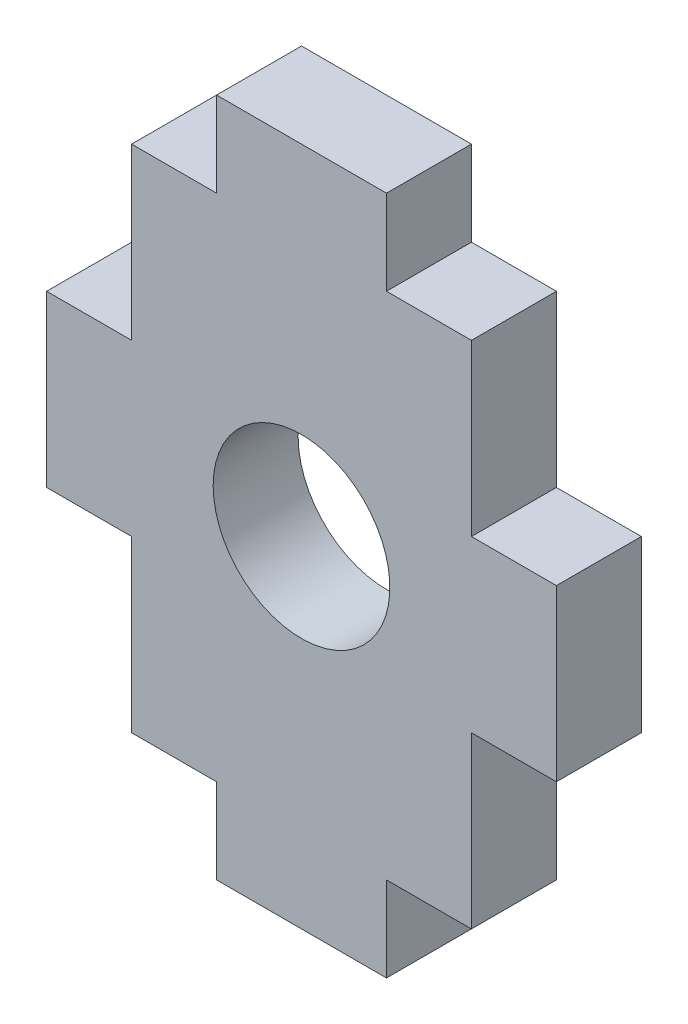
from build123d import *

# Parameters (mm, degrees)
EXTRUDE1_DEPTH     = 3.175
SKETCH2_R          = 3.302
CUT_EXTRUDE1_DEPTH = 3.175


with BuildPart() as part:
    # Sketch1 → Extrude1 (new body)
    with BuildSketch(Plane.XY):
        Polygon((3.175, 9.525), (6.35, 9.525), (6.35, 3.175), (9.525, 3.175), (9.525, -3.175), (6.35, -3.175), (6.35, -9.525), (3.175, -9.525), (3.175, -12.7), (-3.175, -12.7), (-3.175, -9.525), (-6.35, -9.525), (-6.35, -3.175), (-9.525, -3.175), (-9.525, 3.175), (-6.35, 3.175), (-6.35, 9.525), (-3.175, 9.525), (-3.175, 12.7), (3.175, 12.7), align=None)
    extrude(amount=EXTRUDE1_DEPTH)

    # Sketch2 → Cut-Extrude1 (cut)
    with BuildSketch(Plane(origin=(0, 0, 0), x_dir=(-1, 0, 0), z_dir=(0, 0, -1))):
        Circle(SKETCH2_R)
    extrude(amount=-CUT_EXTRUDE1_DEPTH, mode=Mode.SUBTRACT)


solid = part.part
